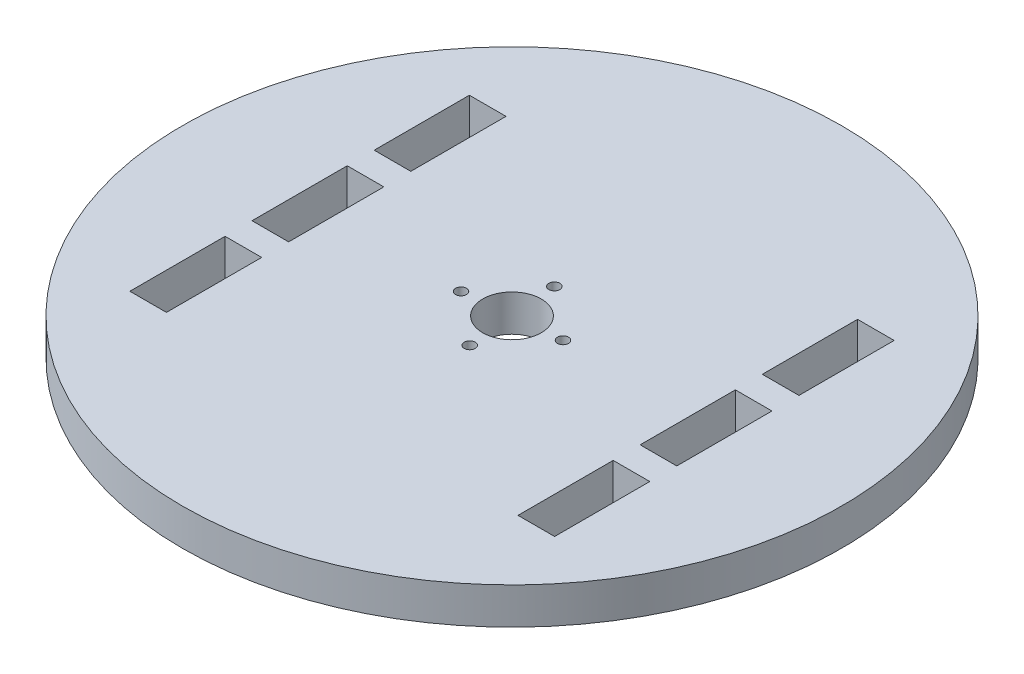
from build123d import *

# Parameters (mm, degrees)
SKETCH1_R           = 45
SKETCH1_R_2         = 4
SKETCH1_R_3         = 0.75
SKETCH1_W           = 5
SKETCH1_H           = 13
BOSS_EXTRUDE1_DEPTH = 5


with BuildPart() as part:
    # Sketch1 → Boss-Extrude1 (new body)
    with BuildSketch(Plane(origin=(0, 0, 0), x_dir=(1, 0, 0), z_dir=(0, 1, 0))):
        Circle(SKETCH1_R)
        Circle(SKETCH1_R_2, mode=Mode.SUBTRACT)
        with Locations((6.368925704, 0.593189593)):
            Circle(SKETCH1_R_3, mode=Mode.SUBTRACT)
        with Locations((0.593189593, -6.368925704)):
            Circle(SKETCH1_R_3, mode=Mode.SUBTRACT)
        with Locations((-0.593189593, 6.368925704)):
            Circle(SKETCH1_R_3, mode=Mode.SUBTRACT)
        with Locations((-6.368925704, -0.593189593)):
            Circle(SKETCH1_R_3, mode=Mode.SUBTRACT)
        with Locations((26.5, -16.682134432)):
            Rectangle(SKETCH1_W, SKETCH1_H, mode=Mode.SUBTRACT)
        with Locations((26.5, 16.682134432)):
            Rectangle(SKETCH1_W, SKETCH1_H, mode=Mode.SUBTRACT)
        with Locations((-26.5, -16.682134432)):
            Rectangle(SKETCH1_W, SKETCH1_H, mode=Mode.SUBTRACT)
        with Locations((26.5, 0)):
            Rectangle(SKETCH1_W, SKETCH1_H, mode=Mode.SUBTRACT)
        with Locations((-26.5, 0)):
            Rectangle(SKETCH1_W, SKETCH1_H, mode=Mode.SUBTRACT)
        with Locations((-26.5, 16.682134432)):
            Rectangle(SKETCH1_W, SKETCH1_H, mode=Mode.SUBTRACT)
    extrude(amount=BOSS_EXTRUDE1_DEPTH)


solid = part.part
